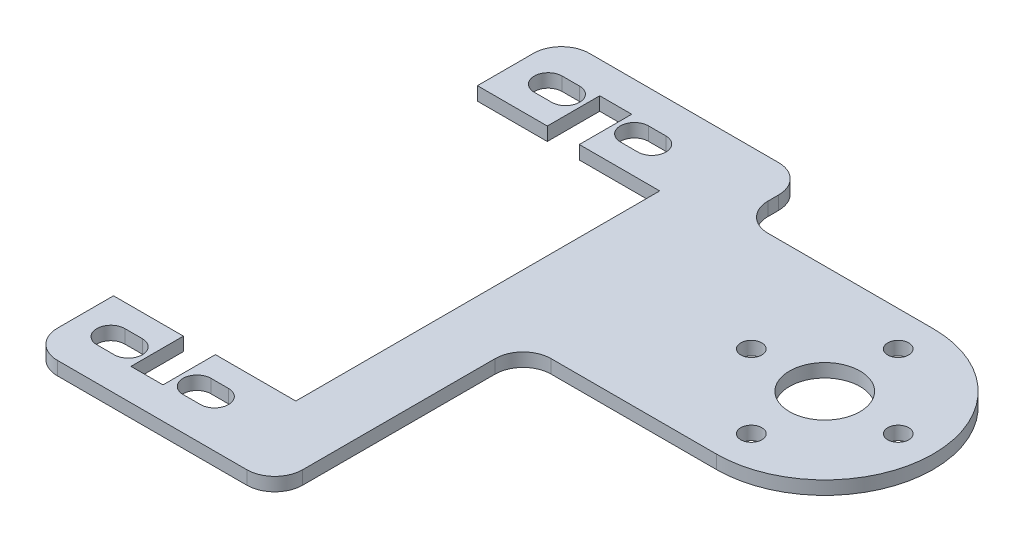
from build123d import *

# Parameters (mm, degrees)
SKETCH1_R      = 4.0005
SKETCH1_R_2    = 1.1938
EXTRUDE1_DEPTH = 1.524


with BuildPart() as part:
    # Sketch1 → Extrude1 (new body)
    with BuildSketch(Plane(origin=(0, 0, 0), x_dir=(1, 0, 0), z_dir=(0, 1, 0))):
        with BuildLine():
            Line((0, 3.175), (0, 9.525))
            Line((0, 9.525), (7.9248, 9.525))
            Line((7.9248, 9.525), (7.9248, 3.5814))
            Line((7.9248, 3.5814), (11.557, 3.5814))
            Line((11.557, 3.5814), (11.557, 9.525))
            Line((11.557, 9.525), (20.6756, 9.525))
            Line((20.6756, 9.525), (20.6756, 50.8))
            Line((20.6756, 50.8), (11.557, 50.8))
            Line((11.557, 50.8), (11.557, 56.7436))
            Line((11.557, 56.7436), (7.9248, 56.7436))
            Line((7.9248, 56.7436), (7.9248, 50.8))
            Line((7.9248, 50.8), (0, 50.8))
            Line((0, 50.8), (0, 57.15))
            ThreePointArc((0, 57.15), (0.92993597, 59.39506403), (3.175, 60.325))
            Line((3.175, 60.325), (24.638, 60.325))
            ThreePointArc((24.638, 60.325), (26.88306403, 59.39506403), (27.813, 57.15))
            Line((27.813, 57.15), (27.813, 55.9562))
            ThreePointArc((27.813, 55.9562), (28.74293597, 53.71113597), (30.988, 52.7812))
            Line((30.988, 52.7812), (49.7205, 52.7812))
            ThreePointArc((49.7205, 52.7812), (62.0268, 40.4749), (49.7205, 28.1686))
            Line((49.7205, 28.1686), (30.988, 28.1686))
            ThreePointArc((30.988, 28.1686), (28.74293597, 27.23866403), (27.813, 24.9936))
            Line((27.813, 24.9936), (27.813, 3.175))
            ThreePointArc((27.813, 3.175), (26.88306403, 0.92993597), (24.638, 0))
            Line((24.638, 0), (3.175, 0))
            ThreePointArc((3.175, 0), (0.92993597, 0.92993597), (0, 3.175))
        make_face()
        with Locations(Location((49.7205, 40.4749, 0), (0, 0, 270))):  # turned: the seam where the file's is
            Circle(SKETCH1_R, mode=Mode.SUBTRACT)
        with Locations(Location((41.3893, 40.4749, 0), (0, 0, 270))):  # turned: the seam where the file's is
            Circle(SKETCH1_R_2, mode=Mode.SUBTRACT)
        with Locations(Location((49.7205, 32.1437, 0), (0, 0, 270))):  # turned: the seam where the file's is
            Circle(SKETCH1_R_2, mode=Mode.SUBTRACT)
        with Locations(Location((58.0517, 40.4749, 0), (0, 0, 270))):  # turned: the seam where the file's is
            Circle(SKETCH1_R_2, mode=Mode.SUBTRACT)
        with Locations(Location((49.7205, 48.8061, 0), (0, 0, 270))):  # turned: the seam where the file's is
            Circle(SKETCH1_R_2, mode=Mode.SUBTRACT)
        with BuildLine():
            Line((5.842, 53.3781), (3.8608, 53.3781))
            ThreePointArc((3.8608, 53.3781), (2.2733, 54.9656), (3.8608, 56.5531))
            Line((3.8608, 56.5531), (5.842, 56.5531))
            ThreePointArc((5.842, 56.5531), (7.4295, 54.9656), (5.842, 53.3781))
        make_face(mode=Mode.SUBTRACT)
        with BuildLine():
            Line((13.6398, 6.9469), (15.621, 6.9469))
            ThreePointArc((15.621, 6.9469), (17.2085, 5.3594), (15.621, 3.7719))
            Line((15.621, 3.7719), (13.6398, 3.7719))
            ThreePointArc((13.6398, 3.7719), (12.0523, 5.3594), (13.6398, 6.9469))
        make_face(mode=Mode.SUBTRACT)
        with BuildLine():
            Line((3.8608, 3.7719), (5.842, 3.7719))
            ThreePointArc((5.842, 3.7719), (7.4295, 5.3594), (5.842, 6.9469))
            Line((5.842, 6.9469), (3.8608, 6.9469))
            ThreePointArc((3.8608, 6.9469), (2.2733, 5.3594), (3.8608, 3.7719))
        make_face(mode=Mode.SUBTRACT)
        with BuildLine():
            Line((15.621, 56.5531), (13.6398, 56.5531))
            ThreePointArc((13.6398, 56.5531), (12.0523, 54.9656), (13.6398, 53.3781))
            Line((13.6398, 53.3781), (15.621, 53.3781))
            ThreePointArc((15.621, 53.3781), (17.2085, 54.9656), (15.621, 56.5531))
        make_face(mode=Mode.SUBTRACT)
    extrude(amount=EXTRUDE1_DEPTH)


solid = part.part
